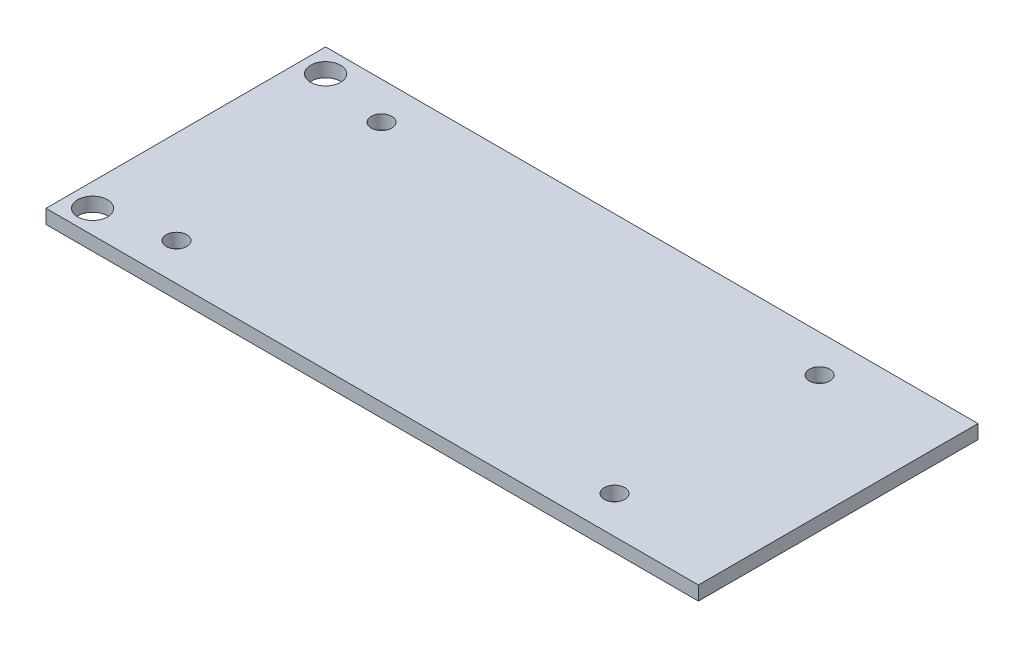
from build123d import *

# Parameters (mm, degrees)
SKETCH_1_W      = 70
SKETCH_1_H      = 30
SKETCH_1_R      = 1.1
SKETCH_1_R_2    = 1.6
EXTRUDE_1_DEPTH = 1.5


with BuildPart() as part:
    # Эскиз1 → Бобышка-Вытянуть1 (new body)
    with BuildSketch(Plane(origin=(0, 0, 0), x_dir=(1, 0, 0), z_dir=(0, 1, 0))):
        with Locations((35, 15)):
            Rectangle(SKETCH_1_W, SKETCH_1_H)
        with Locations((10, 4)):
            Circle(SKETCH_1_R, mode=Mode.SUBTRACT)
        with Locations((57, 4)):
            Circle(SKETCH_1_R, mode=Mode.SUBTRACT)
        with Locations((57, 26)):
            Circle(SKETCH_1_R, mode=Mode.SUBTRACT)
        with Locations((10, 26)):
            Circle(SKETCH_1_R, mode=Mode.SUBTRACT)
        with Locations((2.5, 2.5)):
            Circle(SKETCH_1_R_2, mode=Mode.SUBTRACT)
        with Locations((2.5, 27.5)):
            Circle(SKETCH_1_R_2, mode=Mode.SUBTRACT)
    extrude(amount=EXTRUDE_1_DEPTH)


solid = part.part
